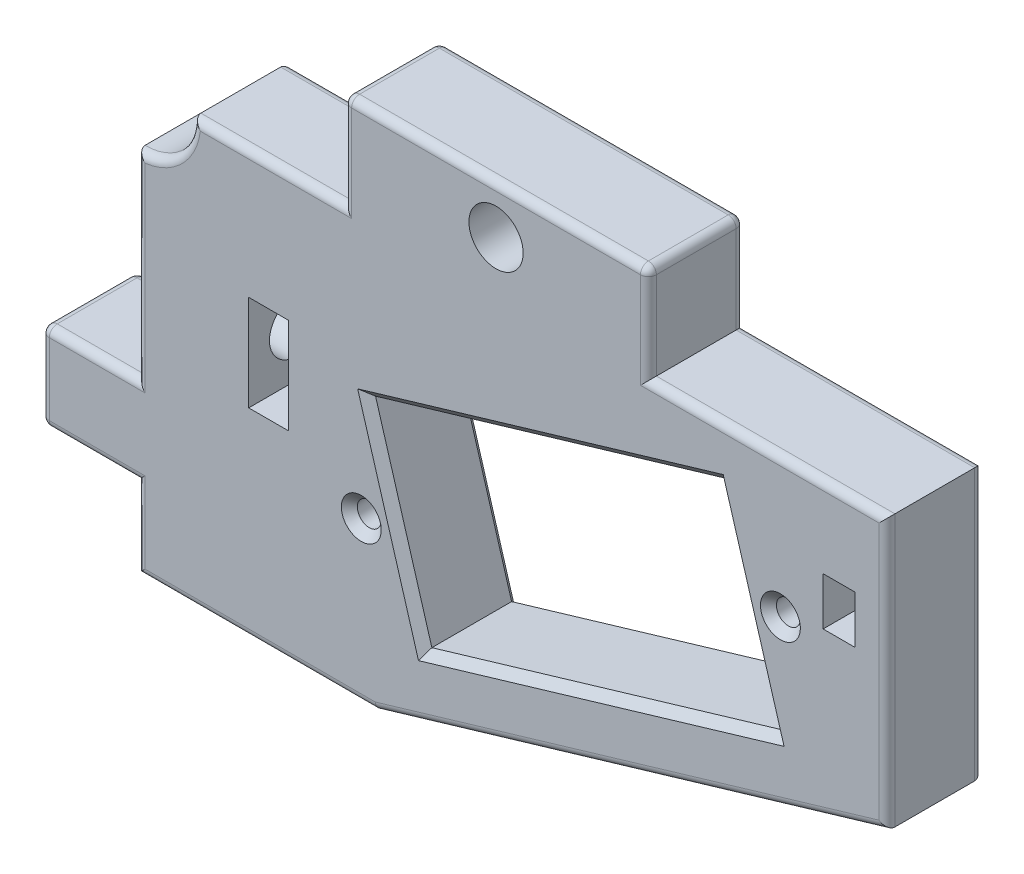
from build123d import *

# Parameters (mm, degrees)
BODY_DEPTH                = 6
SKETCH2_W                 = 19.1
SKETCH2_H                 = 6
TOP_TAB_DEPTH             = 6
SKETCH3_W                 = 6
SKETCH3_H                 = 5.5
BACK_TAB_DEPTH            = 6
SKETCH5_R                 = 1.7
BACK_SCREW_HOLE_DEPTH     = 12
SCREW_AND_NUT_HOLES_REACH = 56.289
SKETCH4_R                 = 1.7
SKETCH4_W                 = 2.5
SKETCH4_H                 = 6
SKETCH7_R                 = 3.5
SWITCH_WIRE_RELIEF_DEPTH  = 55.288580751
FILLET1_R                 = 0.5
SERVO_OPENINGS_REACH      = 56.289
SKETCH6_R                 = 0.75
CHAMFER1_SIZE             = 0.5
SKETCH8_W                 = 2
SKETCH8_H                 = 3
CUT_EXTRUDE1_DEPTH        = 55.288580762


with BuildPart() as part:
    # Sketch1 → Body (new body)
    with BuildSketch(Plane.XY):
        Polygon((0, -26.5), (15, -26.5), (47, -17), (47, 0), (0, 0), align=None)
    extrude(amount=-BODY_DEPTH)

    # Sketch2 → Top Tab (add)
    with BuildSketch(Plane(origin=(0, 0, 0), x_dir=(1, 0, 0), z_dir=(0, 1, 0))):
        with Locations((22.5, 3)):
            Rectangle(SKETCH2_W, SKETCH2_H)
    extrude(amount=TOP_TAB_DEPTH)

    # Sketch3 → Back Tab (add)
    with BuildSketch(Plane.ZY):
        with Locations((-3, -18.69)):
            Rectangle(SKETCH3_W, SKETCH3_H)
    extrude(amount=BACK_TAB_DEPTH)

    # Sketch5 → Back Screw Hole (cut)
    with BuildSketch(Plane.ZY):
        with Locations((-3, -11)):
            Circle(SKETCH5_R)
    extrude(amount=-BACK_SCREW_HOLE_DEPTH, mode=Mode.SUBTRACT)

    # Sketch4 → Screw and Nut Holes (cut, up to next)
    with BuildSketch(Plane.XY, mode=Mode.PRIVATE) as screw_and_nut_holes_sk1:
        with Locations((22.5, 3)):
            Circle(SKETCH4_R)
    screw_and_nut_holes_tool1 = extrude(screw_and_nut_holes_sk1.sketch, amount=-SCREW_AND_NUT_HOLES_REACH, mode=Mode.PRIVATE) & part.part
    # Sketch4 → Screw and Nut Holes (cut, up to next)
    with BuildSketch(Plane.XY, mode=Mode.PRIVATE) as screw_and_nut_holes_sk2:
        with Locations((8.25, -11)):
            Rectangle(SKETCH4_W, SKETCH4_H)
    screw_and_nut_holes_tool2 = extrude(screw_and_nut_holes_sk2.sketch, amount=-SCREW_AND_NUT_HOLES_REACH, mode=Mode.PRIVATE) & part.part
    add(screw_and_nut_holes_tool1.solids().sort_by_distance((22.5, 3, 0))[0], mode=Mode.SUBTRACT)
    add(screw_and_nut_holes_tool2.solids().sort_by_distance((8.25, -11, 0))[0], mode=Mode.SUBTRACT)

    # Sketch7 → Switch Wire Relief (cut, through all)
    with BuildSketch(Plane.XY):
        Circle(SKETCH7_R)
    extrude(amount=-SWITCH_WIRE_RELIEF_DEPTH, mode=Mode.SUBTRACT)

    # Fillet1
    fillet1_edges = [part.edges().sort_by_distance(p)[0] for p in [
        (32.05, 6, -3),
        (12.95, 6, -3),
        (-6, -15.94, -3),
        (-6, -21.44, -3),
        (7.5, -26.5, -6),
        (31, -21.75, -6),
        (47, -8.5, -6),
        (39.525, 0, -6),
        (32.05, 3, -6),
        (22.5, 6, -6),
        (12.95, 3, -6),
        (8.225, 0, -6),
        (0, -9.72, -6),
        (-3, -15.94, -6),
        (-6, -18.69, -6),
        (-3, -21.44, -6),
        (0, -23.97, -6),
        (0, -9.72, 0),
        (8.225, 0, 0),
        (12.95, 3, 0),
        (22.5, 6, 0),
        (32.05, 3, 0),
        (39.525, 0, 0),
        (47, -8.5, 0),
        (31, -21.75, 0),
        (7.5, -26.5, 0),
        (0, -23.97, 0),
        (-3, -21.44, 0),
        (-6, -18.69, 0),
        (-3, -15.94, 0),
        (2.474873734, -2.474873734, -6),
        (2.474873734, -2.474873734, 0),
    ]]
    fillet(fillet1_edges, radius=FILLET1_R)

    # Sketch6 → Servo Openings (cut, up to next)
    with BuildSketch(Plane.XY, mode=Mode.PRIVATE) as servo_openings_sk1:
        with Locations((14.056274553, -16.473540836)):
            Circle(SKETCH6_R)
    servo_openings_tool1 = extrude(servo_openings_sk1.sketch, amount=-SERVO_OPENINGS_REACH, mode=Mode.PRIVATE) & part.part
    # Sketch6 → Servo Openings (cut, up to next)
    with BuildSketch(Plane.XY, mode=Mode.PRIVATE) as servo_openings_sk2:
        with Locations((40.323198689, -8.675547733)):
            Circle(SKETCH6_R)
    servo_openings_tool2 = extrude(servo_openings_sk2.sketch, amount=-SERVO_OPENINGS_REACH, mode=Mode.PRIVATE) & part.part
    # Sketch6 → Servo Openings (cut, up to next)
    with BuildSketch(Plane.XY, mode=Mode.PRIVATE) as servo_openings_sk3:
        Polygon((36.401733852, -3.372283311), (39.930752628, -15.259504453), (17.97773939, -21.776805258), (14.448720614, -9.889584116), align=None)
    servo_openings_tool3 = extrude(servo_openings_sk3.sketch, amount=-SERVO_OPENINGS_REACH, mode=Mode.PRIVATE) & part.part
    add(servo_openings_tool1.solids().sort_by_distance((14.056275, -16.473541, 0))[0], mode=Mode.SUBTRACT)
    add(servo_openings_tool2.solids().sort_by_distance((40.323199, -8.675548, 0))[0], mode=Mode.SUBTRACT)
    add(servo_openings_tool3.solids().sort_by_distance((27.189737, -12.574544, 0))[0], mode=Mode.SUBTRACT)

    # Chamfer1
    chamfer1_edges = [part.edges().sort_by_distance(p)[0] for p in [
        (39.573198689, -8.675547733, -6),
        (13.306274553, -16.473540836, -6),
        (16.213230002, -15.833194687, -6),
        (25.425227233, -6.630933714, -6),
        (38.16624324, -9.315893882, -6),
        (28.954246009, -18.518154856, -6),
        (13.306274553, -16.473540836, 0),
        (39.573198689, -8.675547733, 0),
        (16.213230002, -15.833194687, 0),
        (25.425227233, -6.630933714, 0),
        (38.16624324, -9.315893882, 0),
        (28.954246009, -18.518154856, 0),
    ]]
    chamfer(chamfer1_edges, length=CHAMFER1_SIZE)

    # Sketch8 → Cut-Extrude1 (cut, through all)
    with BuildSketch(Plane.XY):
        with Locations((44, -6.5)):
            Rectangle(SKETCH8_W, SKETCH8_H)
    extrude(amount=-CUT_EXTRUDE1_DEPTH, mode=Mode.SUBTRACT)


solid = part.part
